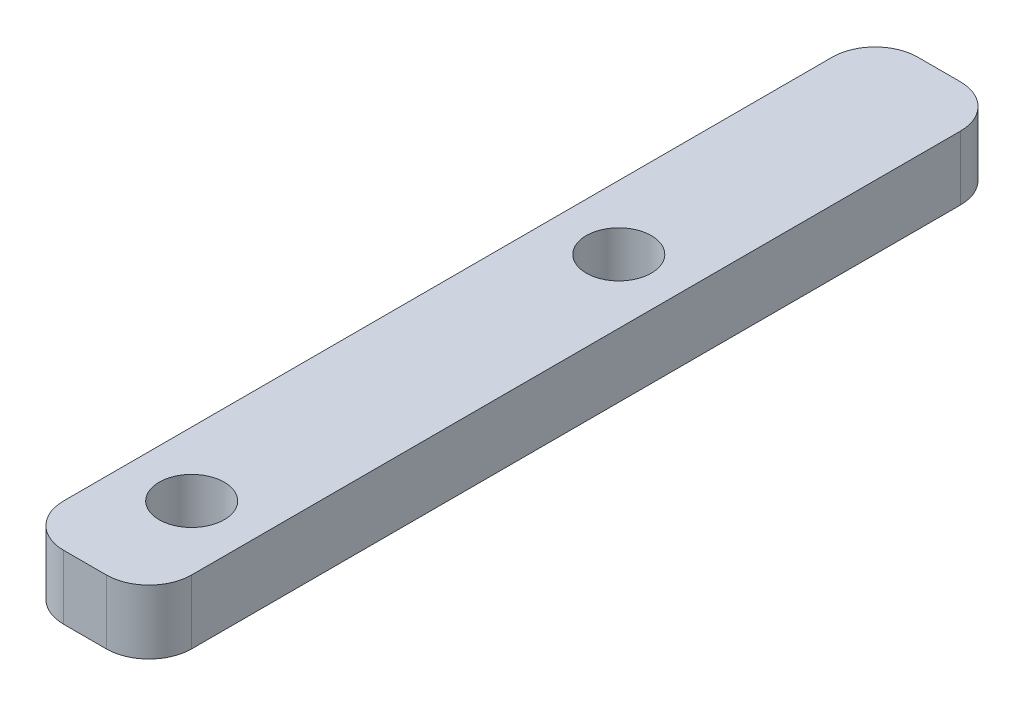
from build123d import *

# Parameters (mm, degrees)
SKETCH_1_W          = 6
SKETCH_1_H          = 40
EXTRUDE_1_DEPTH     = 3
FILLET_1_R          = 2
SKETCH_2_R          = 1.525
CUT_EXTRUDE_1_DEPTH = 3


with BuildPart() as part:
    # 草图1 → 凸台-拉伸1 (new body)
    with BuildSketch(Plane(origin=(0, 0, 0), x_dir=(1, 0, 0), z_dir=(0, 1, 0))):
        Rectangle(SKETCH_1_W, SKETCH_1_H)
    extrude(amount=EXTRUDE_1_DEPTH)

    # 圆角1
    fillet_1_edges = [part.edges().sort_by_distance(p)[0] for p in [
        (3, 1.5, 20),
        (-3, 1.5, 20),
        (-3, 1.5, -20),
        (3, 1.5, -20),
    ]]
    fillet(fillet_1_edges, radius=FILLET_1_R)

    # 草图2 → 切除-拉伸1 (cut)
    with BuildSketch(Plane(origin=(0, 3, 0), x_dir=(1, 0, 0), z_dir=(0, 1, 0))):
        with Locations((0, 5)):
            Circle(SKETCH_2_R)
        with Locations((0, -15)):
            Circle(SKETCH_2_R)
    extrude(amount=-CUT_EXTRUDE_1_DEPTH, mode=Mode.SUBTRACT)


solid = part.part
